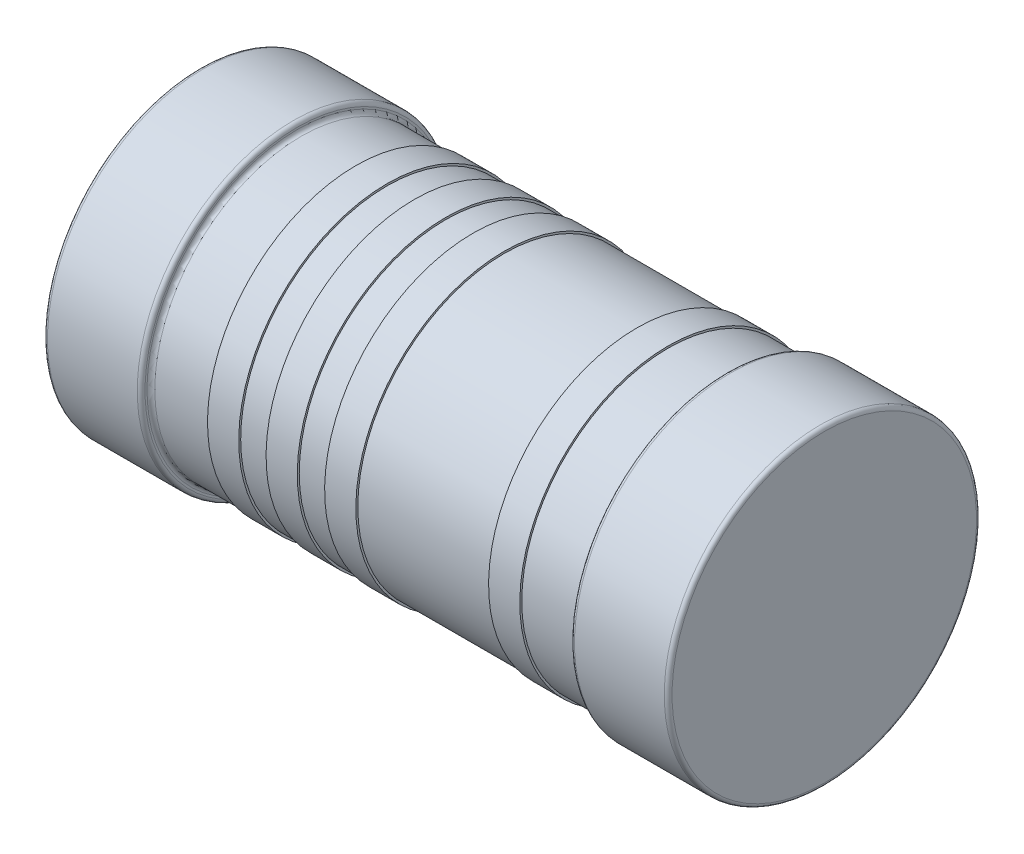
from build123d import *


with BuildPart() as part:
    # Sketch1 → Revolve1 (revolve)
    with BuildSketch(Plane.XY):
        with BuildLine():
            Line((-1.6, 0.8), (1.6, 0.8))
            Line((1.6, 0.8), (1.6, 0.02))
            ThreePointArc((1.6, 0.02), (1.594142136, 0.005857864), (1.58, 0))
            Line((1.58, 0), (1.12, 0))
            ThreePointArc((1.12, 0), (1.105857864, 0.005857864), (1.1, 0.02))
            Line((1.1, 0.02), (1.1, 0.03))
            ThreePointArc((1.1, 0.03), (1.094142136, 0.044142136), (1.08, 0.05))
            Line((1.08, 0.05), (0.8, 0.05))
            Line((0.8, 0.05), (0.8, 0.04))
            Line((0.8, 0.04), (0.64, 0.04))
            Line((0.64, 0.04), (0.64, 0.05))
            Line((0.64, 0.05), (-0.04, 0.05))
            Line((-0.04, 0.05), (-0.04, 0.04))
            Line((-0.04, 0.04), (-0.2, 0.04))
            Line((-0.2, 0.04), (-0.2, 0.05))
            Line((-0.2, 0.05), (-0.34, 0.05))
            Line((-0.34, 0.05), (-0.34, 0.04))
            Line((-0.34, 0.04), (-0.5, 0.04))
            Line((-0.5, 0.04), (-0.5, 0.05))
            Line((-0.5, 0.05), (-0.64, 0.05))
            Line((-0.64, 0.05), (-0.64, 0.04))
            Line((-0.64, 0.04), (-0.8, 0.04))
            Line((-0.8, 0.04), (-0.8, 0.05))
            Line((-0.8, 0.05), (-1.08, 0.05))
            ThreePointArc((-1.08, 0.05), (-1.094142136, 0.044142136), (-1.1, 0.03))
            Line((-1.1, 0.03), (-1.1, 0.02))
            ThreePointArc((-1.1, 0.02), (-1.105857864, 0.005857864), (-1.12, 0))
            Line((-1.12, 0), (-1.58, 0))
            ThreePointArc((-1.58, 0), (-1.594142136, 0.005857864), (-1.6, 0.02))
            Line((-1.6, 0.02), (-1.6, 0.8))
        make_face()
    revolve(axis=Axis((-1.6, 0.8, 0), (-1, 0, 0)))


solid = part.part
